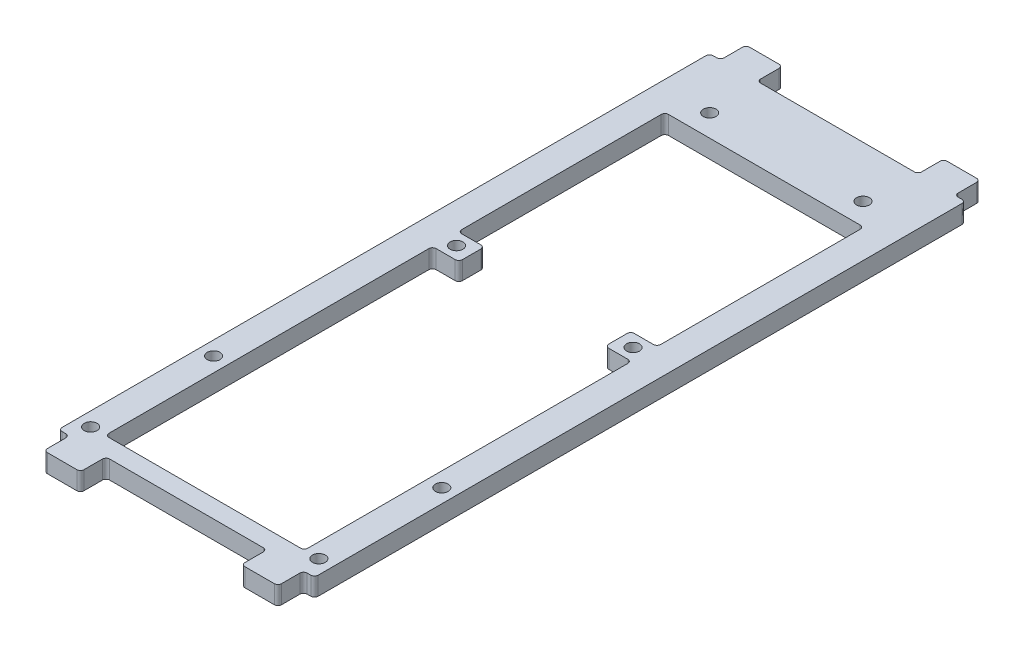
from build123d import *

# Parameters (mm, degrees)
BOSS_EXTRUDE1_DEPTH = 5
SKETCH2_R           = 1.75
CUT_EXTRUDE1_DEPTH  = 10
SKETCH3_R           = 1.75
CUT_EXTRUDE2_DEPTH  = 10
CUT_EXTRUDE3_DEPTH  = 65
SKETCH5_W           = 54.4
SKETCH5_H           = 38
CUT_EXTRUDE4_DEPTH  = 5
CUT_EXTRUDE5_DEPTH  = 5


with BuildPart() as part:
    # Sketch1 → Boss-Extrude1 (new body)
    with BuildSketch(Plane(origin=(0, 0, 0), x_dir=(1, 0, 0), z_dir=(0, 1, 0))):
        with BuildLine():
            Line((34, -89), (33, -89))
            ThreePointArc((33, -89), (32.292893219, -89.292893219), (32, -90))
            Line((32, -90), (32, -95))
            ThreePointArc((32, -95), (31.707106781, -95.707106781), (31, -96))
            Line((31, -96), (23, -96))
            ThreePointArc((23, -96), (22.292893219, -95.707106781), (22, -95))
            Line((22, -95), (22, -90))
            ThreePointArc((22, -90), (21.707106781, -89.292893219), (21, -89))
            Line((21, -89), (-21, -89))
            ThreePointArc((-21, -89), (-21.707106781, -89.292893219), (-22, -90))
            Line((-22, -90), (-22, -95))
            ThreePointArc((-22, -95), (-22.292893219, -95.707106781), (-23, -96))
            Line((-23, -96), (-31, -96))
            ThreePointArc((-31, -96), (-31.707106781, -95.707106781), (-32, -95))
            Line((-32, -95), (-32, -90))
            ThreePointArc((-32, -90), (-32.292893219, -89.292893219), (-33, -89))
            Line((-33, -89), (-34, -89))
            ThreePointArc((-34, -89), (-34.707106781, -88.707106781), (-35, -88))
            Line((-35, -88), (-35, 88))
            ThreePointArc((-35, 88), (-34.707106781, 88.707106781), (-34, 89))
            Line((-34, 89), (-33, 89))
            ThreePointArc((-33, 89), (-32.292893219, 89.292893219), (-32, 90))
            Line((-32, 90), (-32, 95))
            ThreePointArc((-32, 95), (-31.707106781, 95.707106781), (-31, 96))
            Line((-31, 96), (-23, 96))
            ThreePointArc((-23, 96), (-22.292893219, 95.707106781), (-22, 95))
            Line((-22, 95), (-22, 90))
            ThreePointArc((-22, 90), (-21.707106781, 89.292893219), (-21, 89))
            Line((-21, 89), (21, 89))
            ThreePointArc((21, 89), (21.707106781, 89.292893219), (22, 90))
            Line((22, 90), (22, 95))
            ThreePointArc((22, 95), (22.292893219, 95.707106781), (23, 96))
            Line((23, 96), (31, 96))
            ThreePointArc((31, 96), (31.707106781, 95.707106781), (32, 95))
            Line((32, 95), (32, 90))
            ThreePointArc((32, 90), (32.292893219, 89.292893219), (33, 89))
            Line((33, 89), (34, 89))
            ThreePointArc((34, 89), (34.707106781, 88.707106781), (35, 88))
            Line((35, 88), (35, -88))
            ThreePointArc((35, -88), (34.707106781, -88.707106781), (34, -89))
        make_face()
    extrude(amount=BOSS_EXTRUDE1_DEPTH)

    # Sketch2 → Cut-Extrude1 (cut)
    with BuildSketch(Plane(origin=(0, 5, 0), x_dir=(1, 0, 0), z_dir=(0, 1, 0))):
        with Locations((-20.955, 75)):
            Circle(SKETCH2_R)
        with Locations((-24.13, 8.96)):
            Circle(SKETCH2_R)
        with Locations((20.955, 75)):
            Circle(SKETCH2_R)
        with Locations((24.13, 8.96)):
            Circle(SKETCH2_R)
    extrude(amount=-CUT_EXTRUDE1_DEPTH, mode=Mode.SUBTRACT)

    # Sketch3 → Cut-Extrude2 (cut)
    with BuildSketch(Plane(origin=(0, 5, 0), x_dir=(1, 0, 0), z_dir=(0, 1, 0))):
        with Locations((-31.2, -84)):
            Circle(SKETCH3_R)
        with Locations((31.2, -84)):
            Circle(SKETCH3_R)
        with Locations((31.2, -50.4)):
            Circle(SKETCH3_R)
        with Locations((-31.2, -50.4)):
            Circle(SKETCH3_R)
    extrude(amount=-CUT_EXTRUDE2_DEPTH, mode=Mode.SUBTRACT)

    # Sketch4 → Cut-Extrude3 (cut)
    with BuildSketch(Plane(origin=(0, 5, 0), x_dir=(1, 0, 0), z_dir=(0, 1, 0))):
        with BuildLine():
            Line((-26.2, -84), (26.2, -84))
            ThreePointArc((26.2, -84), (26.907106781, -83.707106781), (27.2, -83))
            Line((27.2, -83), (27.2, -50.4))
            Line((27.2, -50.4), (-27.2, -50.4))
            Line((-27.2, -50.4), (-27.2, -72.4))
            Line((-27.2, -72.4), (-27.2, -83))
            ThreePointArc((-27.2, -83), (-26.907106781, -83.707106781), (-26.2, -84))
        make_face()
    extrude(amount=-CUT_EXTRUDE3_DEPTH, mode=Mode.SUBTRACT)

    # Sketch5 → Cut-Extrude4 (cut)
    with BuildSketch(Plane(origin=(0, 5, 0), x_dir=(1, 0, 0), z_dir=(0, 1, 0))):
        with Locations((0, -31.4)):
            Rectangle(SKETCH5_W, SKETCH5_H)
    extrude(amount=-CUT_EXTRUDE4_DEPTH, mode=Mode.SUBTRACT)

    # Sketch6 → Cut-Extrude5 (cut)
    with BuildSketch(Plane(origin=(0, 5, 0), x_dir=(1, 0, 0), z_dir=(0, 1, 0))):
        with BuildLine():
            Line((26.2, 12.46), (21, 12.46))
            ThreePointArc((21, 12.46), (20.292893219, 12.167106781), (20, 11.46))
            Line((20, 11.46), (20, 6.46))
            ThreePointArc((20, 6.46), (20.292893219, 5.752893219), (21, 5.46))
            Line((21, 5.46), (26.2, 5.46))
            ThreePointArc((26.2, 5.46), (26.907106781, 5.167106781), (27.2, 4.46))
            Line((27.2, 4.46), (27.2, -12.54))
            Line((27.2, -12.54), (16, -12.54))
            Line((16, -12.54), (-20, -12.54))
            Line((-20, -12.54), (-27.2, -12.54))
            Line((-27.2, -12.54), (-27.2, 4.46))
            ThreePointArc((-27.2, 4.46), (-26.907106781, 5.167106781), (-26.2, 5.46))
            Line((-26.2, 5.46), (-21, 5.46))
            ThreePointArc((-21, 5.46), (-20.292893219, 5.752893219), (-20, 6.46))
            Line((-20, 6.46), (-20, 11.46))
            ThreePointArc((-20, 11.46), (-20.292893219, 12.167106781), (-21, 12.46))
            Line((-21, 12.46), (-26.2, 12.46))
            ThreePointArc((-26.2, 12.46), (-26.907106781, 12.752893219), (-27.2, 13.46))
            Line((-27.2, 13.46), (-27.2, 68))
            ThreePointArc((-27.2, 68), (-26.907106781, 68.707106781), (-26.2, 69))
            Line((-26.2, 69), (26.2, 69))
            ThreePointArc((26.2, 69), (26.907106781, 68.707106781), (27.2, 68))
            Line((27.2, 68), (27.2, 13.46))
            ThreePointArc((27.2, 13.46), (26.907106781, 12.752893219), (26.2, 12.46))
        make_face()
    extrude(amount=-CUT_EXTRUDE5_DEPTH, mode=Mode.SUBTRACT)


solid = part.part
